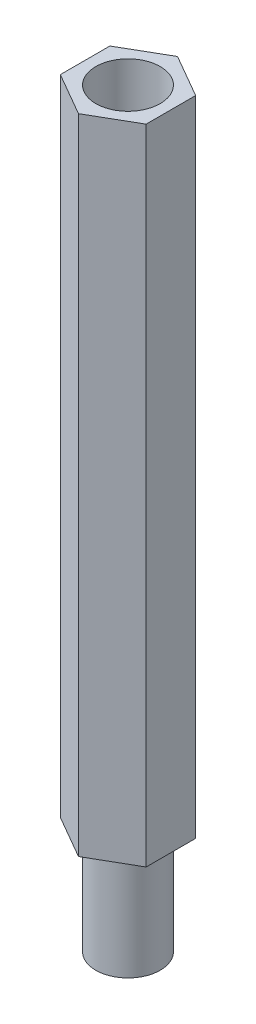
from build123d import *

# Parameters (mm, degrees)
SKETCH_1_R          = 1.5
EXTRUDE_1_DEPTH     = 5
EXTRUDE_2_DEPTH     = 30
SKETCH_3_R          = 1.5
CUT_EXTRUDE_1_DEPTH = 5


with BuildPart() as part:
    # 草图1 → 凸台-拉伸1 (new body)
    with BuildSketch(Plane(origin=(0, 0, 0), x_dir=(1, 0, 0), z_dir=(0, 1, 0))):
        Circle(SKETCH_1_R)
    extrude(amount=EXTRUDE_1_DEPTH)

    # 草图2 → 凸台-拉伸2 (add)
    with BuildSketch(Plane(origin=(0, 5, 0), x_dir=(1, 0, 0), z_dir=(0, 1, 0))):
        Polygon((0, 2.309401077), (-2, 1.154700538), (-2, -1.154700538), (0, -2.309401077), (2, -1.154700538), (2, 1.154700538), align=None)
    extrude(amount=EXTRUDE_2_DEPTH)

    # 草图3 → 切除-拉伸1 (cut)
    with BuildSketch(Plane(origin=(0, 35, 0), x_dir=(1, 0, 0), z_dir=(0, 1, 0))):
        Circle(SKETCH_3_R)
    extrude(amount=-CUT_EXTRUDE_1_DEPTH, mode=Mode.SUBTRACT)


solid = part.part
